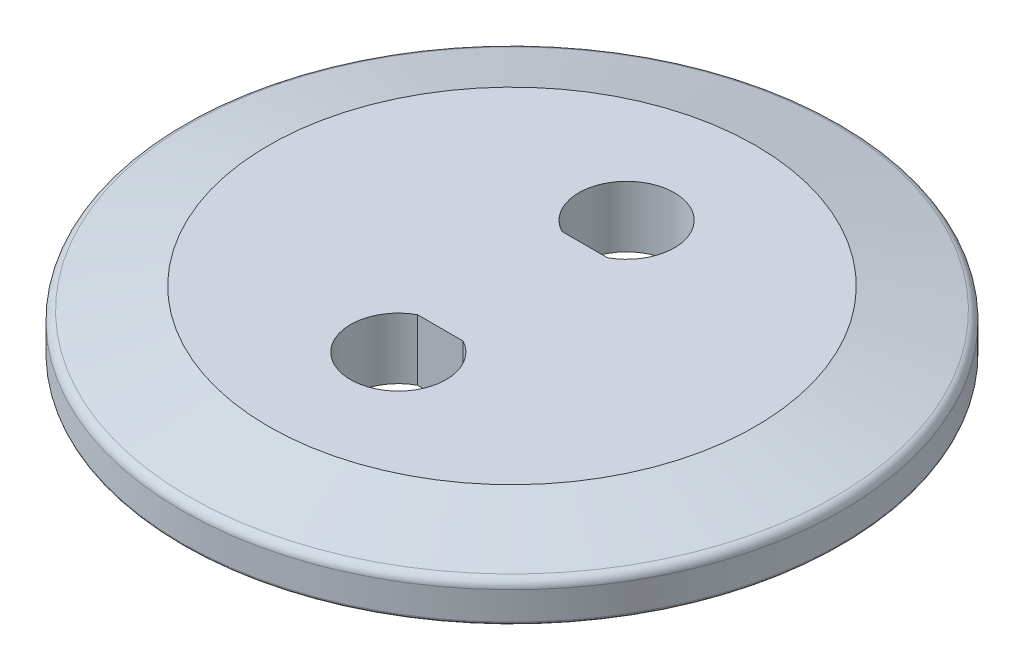
from build123d import *

# Parameters (mm, degrees)
SKETCH2_W          = 15.85
SKETCH2_H          = 2.5
FILLET1_R          = 0.762
FILLET2_R          = 0.254
CUT_EXTRUDE1_DEPTH = 6.1


with BuildPart() as part:
    # Sketch1 → Flange (revolve)
    with BuildSketch(Plane(origin=(0, 0, 0), x_dir=(0, 0, -1), z_dir=(1, 0, 0))):
        Polygon((-27.5, 0), (-27.5, 3.175), (-20.315802195, 5.1), (0, 5.1), (0, 2.5), (-20.625, 2.5), (-20.625, 0), align=None)
    revolve(axis=Axis((0, 0, 0), (0, 1, 0)))

    # Sketch2 → Blank Insert (revolve)
    with BuildSketch(Plane(origin=(0, 0, 0), x_dir=(0, 0, -1), z_dir=(1, 0, 0))):
        with Locations((-7.925, 1.25)):
            Rectangle(SKETCH2_W, SKETCH2_H)
    revolve(axis=Axis((0, 0, 0), (0, -1, 0)))

    # Fillet1
    fillet1_edges = [part.edges().sort_by_distance(p)[0] for p in [
        (0, 3.175, -27.5),
    ]]
    fillet(fillet1_edges, radius=FILLET1_R)

    # Fillet2
    fillet2_edges = [part.edges().sort_by_distance(p)[0] for p in [
        (0, 0, -27.5),
    ]]
    fillet(fillet2_edges, radius=FILLET2_R)

    # Sketch3 → Cut-Extrude1 (cut, through all)
    with BuildSketch(Plane(origin=(0, 5.1, 0), x_dir=(1, 0, 0), z_dir=(0, 1, 0))):
        with BuildLine():
            Line((-1.862547623, 6.0198), (1.940673012, 6.0198))
            ThreePointArc((1.940673012, 6.0198), (0.039062695, 13.5128), (-1.862547623, 6.0198))
        make_face()
    cut_extrude1 = extrude(amount=-CUT_EXTRUDE1_DEPTH, mode=Mode.SUBTRACT)

    # Mirror1: Cut-Extrude1 across plane
    add(cut_extrude1.mirror(Plane.XY), mode=Mode.SUBTRACT)


solid = part.part
